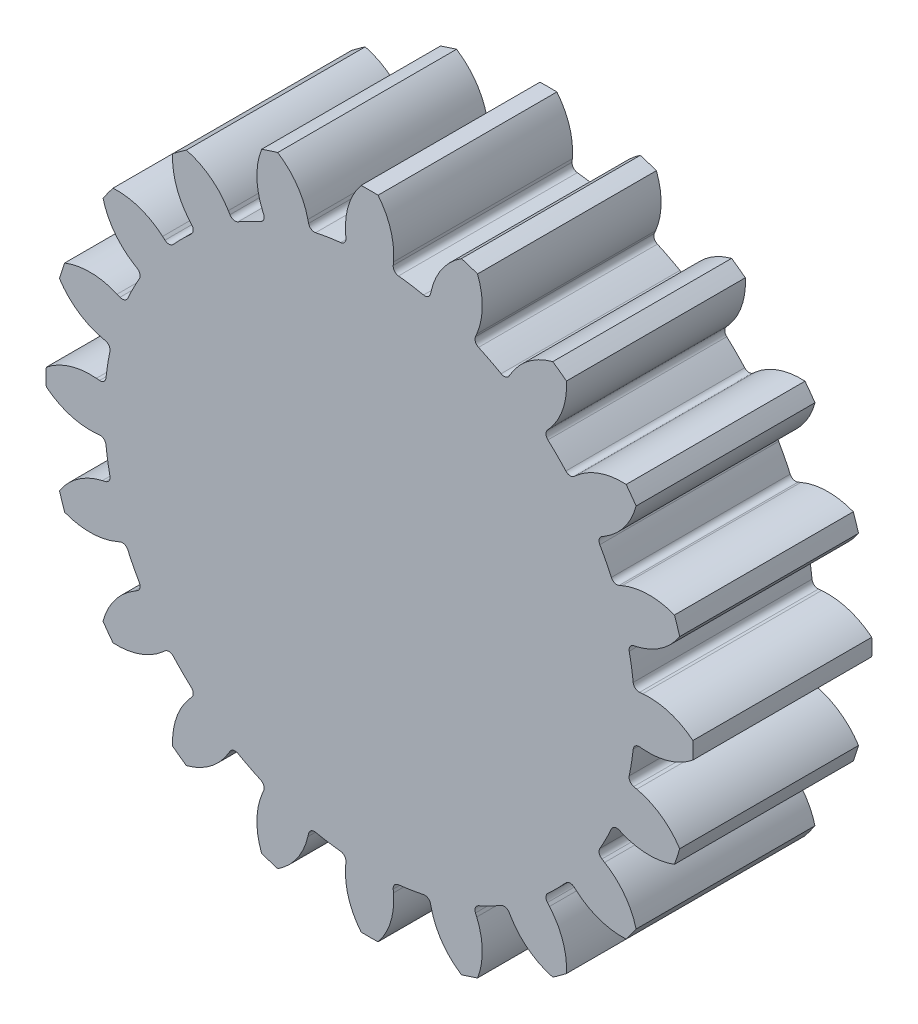
from build123d import *

# Parameters (mm, degrees)
BOSS_EXTRUDE2_DEPTH      = 6
FILLET3_R                = 0.2
FILLET4_R                = 0.2
CIRPATTERN2_COUNT        = 20
FILLET3_OF_CIRPATTERN2_R = 0.2
FILLET4_OF_CIRPATTERN2_R = 0.2


with BuildPart() as part:
    # Sketch1 → Boss-Extrude2 (new body)
    with BuildSketch(Plane.XY):
        with BuildLine():
            Line((9.164991222, 0.801832833), (8.862495798, 0.775367913))
            ThreePointArc((8.862495798, 0.775367913), (8.830037055, 1.084192223), (8.786820273, 1.391695611))
            Line((8.786820273, 1.391695611), (0, 0))
            Line((0, 0), (8.786820273, -1.391695611))
            ThreePointArc((8.786820273, -1.391695611), (8.830037055, -1.084192223), (8.862495798, -0.775367913))
            Line((8.862495798, -0.775367913), (9.164991222, -0.801832833))
            ThreePointArc((9.164991222, -0.801832833), (10.056239811, -0.707230312), (10.846281976, -0.284019889))
            ThreePointArc((10.846281976, -0.284019889), (10.85, 0), (10.846281976, 0.284019889))
            ThreePointArc((10.846281976, 0.284019889), (10.056239811, 0.707230312), (9.164991222, 0.801832833))
        make_face()
    boss_extrude2 = extrude(amount=BOSS_EXTRUDE2_DEPTH)

    # Fillet3
    fillet3_edges = [part.edges().sort_by_distance(p)[0] for p in [
        (8.862495798, 0.775367913, 3),
    ]]
    fillet(fillet3_edges, radius=FILLET3_R)

    # Fillet4
    fillet4_edges = [part.edges().sort_by_distance(p)[0] for p in [
        (8.862495798, -0.775367913, 3),
    ]]
    fillet(fillet4_edges, radius=FILLET4_R)

    # CirPattern2: Boss-Extrude2 ×20 about axis
    cirpattern2_axis = Axis((0, 0, 0), (0, 0, 1))
    for i in range(1, CIRPATTERN2_COUNT):
        add(boss_extrude2.rotate(cirpattern2_axis, i * 360 / CIRPATTERN2_COUNT))

    # Fillet3 of CirPattern2
    fillet3_of_cirpattern2_edges = [part.edges().sort_by_distance(p)[0] for p in [
        (8.189132518, 3.47608052, 3),
        (6.714159889, 5.836530147, 3),
        (4.58195851, 7.625659538, 3),
        (2.001243108, 8.668336242, 3),
        (-0.775367913, 8.862495798, 3),
        (-3.47608052, 8.189132518, 3),
        (-5.836530147, 6.714159889, 3),
        (-7.625659538, 4.58195851, 3),
        (-8.668336242, 2.001243108, 3),
        (-8.862495798, -0.775367913, 3),
        (-8.189132518, -3.47608052, 3),
        (-6.714159889, -5.836530147, 3),
        (-4.58195851, -7.625659538, 3),
        (-2.001243108, -8.668336242, 3),
        (0.775367913, -8.862495798, 3),
        (3.47608052, -8.189132518, 3),
        (5.836530147, -6.714159889, 3),
        (7.625659538, -4.58195851, 3),
        (8.668336242, -2.001243108, 3),
    ]]
    fillet(fillet3_of_cirpattern2_edges, radius=FILLET3_OF_CIRPATTERN2_R)

    # Fillet4 of CirPattern2
    fillet4_of_cirpattern2_edges = [part.edges().sort_by_distance(p)[0] for p in [
        (8.668336242, 2.001243108, 3),
        (7.625659538, 4.58195851, 3),
        (5.836530147, 6.714159889, 3),
        (3.47608052, 8.189132518, 3),
        (0.775367913, 8.862495798, 3),
        (-2.001243108, 8.668336242, 3),
        (-4.58195851, 7.625659538, 3),
        (-6.714159889, 5.836530147, 3),
        (-8.189132518, 3.47608052, 3),
        (-8.862495798, 0.775367913, 3),
        (-8.668336242, -2.001243108, 3),
        (-7.625659538, -4.58195851, 3),
        (-5.836530147, -6.714159889, 3),
        (-3.47608052, -8.189132518, 3),
        (-0.775367913, -8.862495798, 3),
        (2.001243108, -8.668336242, 3),
        (4.58195851, -7.625659538, 3),
        (6.714159889, -5.836530147, 3),
        (8.189132518, -3.47608052, 3),
    ]]
    fillet(fillet4_of_cirpattern2_edges, radius=FILLET4_OF_CIRPATTERN2_R)


solid = part.part
